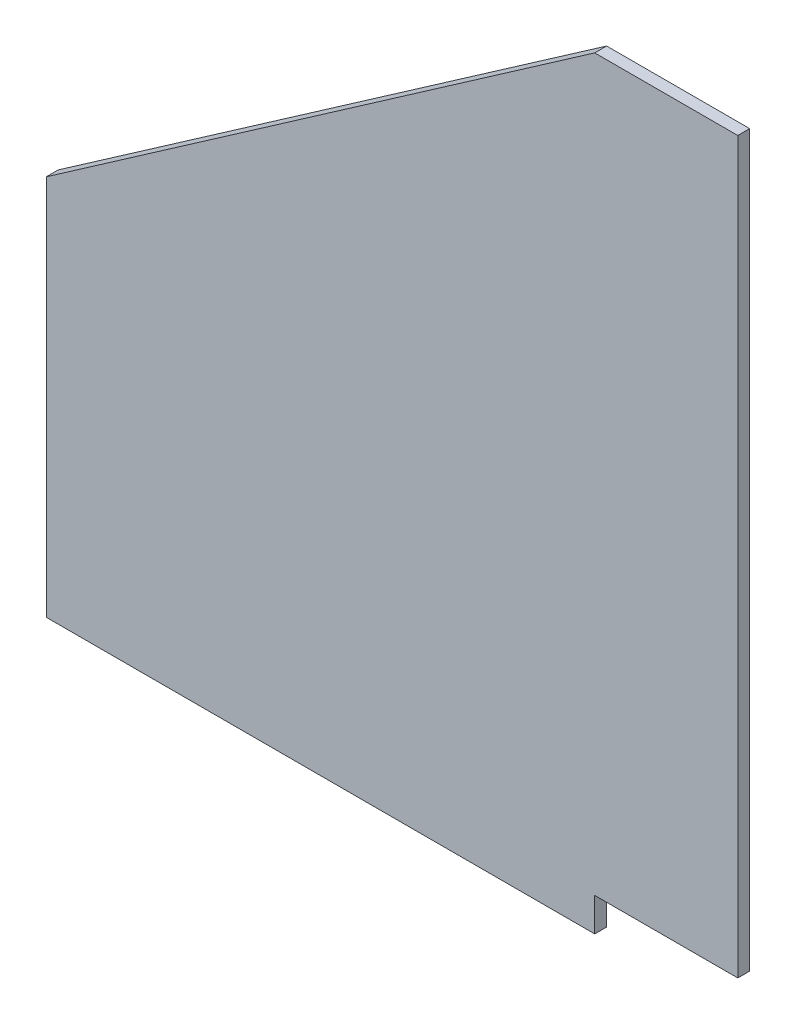
from build123d import *

# Parameters (mm, degrees)
BOSS_EXTRUDE1_DEPTH = 3.175


with BuildPart() as part:
    # Sketch1 → Boss-Extrude1 (new body)
    with BuildSketch(Plane.XY):
        Polygon((0, 0), (0, 194.31), (-38.1, 194.31), (-184.15, 92.71), (-184.15, -8.89), (-38.1, -8.89), (-38.1, 0), align=None)
    extrude(amount=BOSS_EXTRUDE1_DEPTH)


solid = part.part
